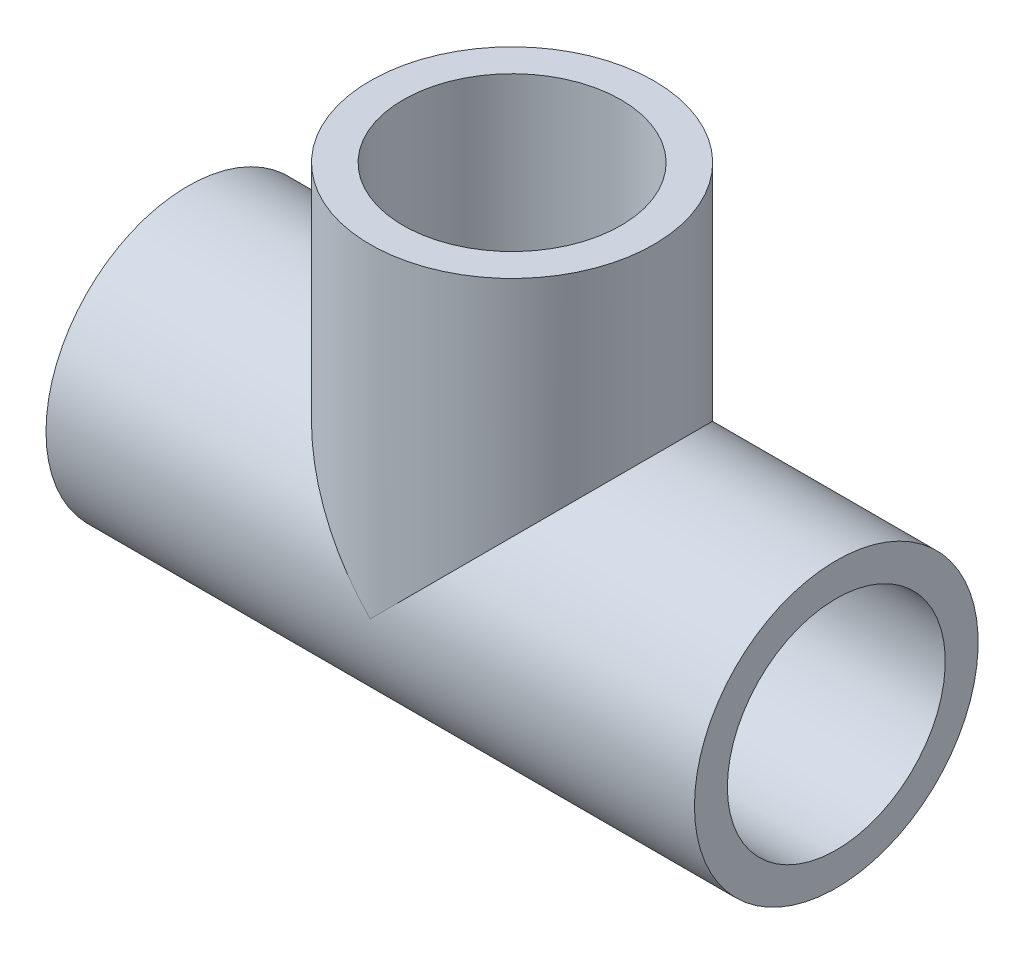
from build123d import *

# Parameters (mm, degrees)
SKETCH2_W               = 13.890625
SKETCH2_H               = 31.75
CUT_EXTRUDE1_DEPTH      = 48.000792219
CUT_EXTRUDE1_DEPTH_BACK = 48.000792219
SKETCH4_R               = 6.9342


with BuildPart() as part:
    # Sketch1 → Revolve1 (revolve)
    with BuildSketch(Plane.XY):
        Polygon((-31.75, 13.890625), (31.75, 13.890625), (31.75, 10.668), (12.7, 10.668), (12.7, 0), (-12.7, 0), (-12.7, 10.668), (-31.75, 10.668), align=None)
    revolve(axis=Axis((0, 0, 0), (1, 0, 0)))

    # Sketch2 → Revolve2 (revolve)
    with BuildSketch(Plane.XY):
        with Locations((-6.9453125, 15.875)):
            Rectangle(SKETCH2_W, SKETCH2_H)
    revolve(axis=Axis((0, 38.237555026, 0), (0, 1, 0)))

    # Sketch3 → Cut-Revolve1 (revolve, cut)
    with BuildSketch(Plane.XY):
        Polygon((0, 31.75), (-10.668, 31.75), (-10.668, 12.7), (-6.9342, 12.7), (-6.9342, 0), (0, 0), align=None)
    revolve(axis=Axis((0, 78.208657222, 0), (0, 1, 0)), mode=Mode.SUBTRACT)

    # Sketch4 → Cut-Extrude1 (cut, two sides: drawn at the far end of the back side and taken through both)
    with BuildSketch(Plane(origin=(0, 0, 0), x_dir=(0, 0, -1), z_dir=(1, 0, 0)).offset(-CUT_EXTRUDE1_DEPTH_BACK)):
        Circle(SKETCH4_R)
    extrude(amount=CUT_EXTRUDE1_DEPTH + CUT_EXTRUDE1_DEPTH_BACK, mode=Mode.SUBTRACT)


solid = part.part
